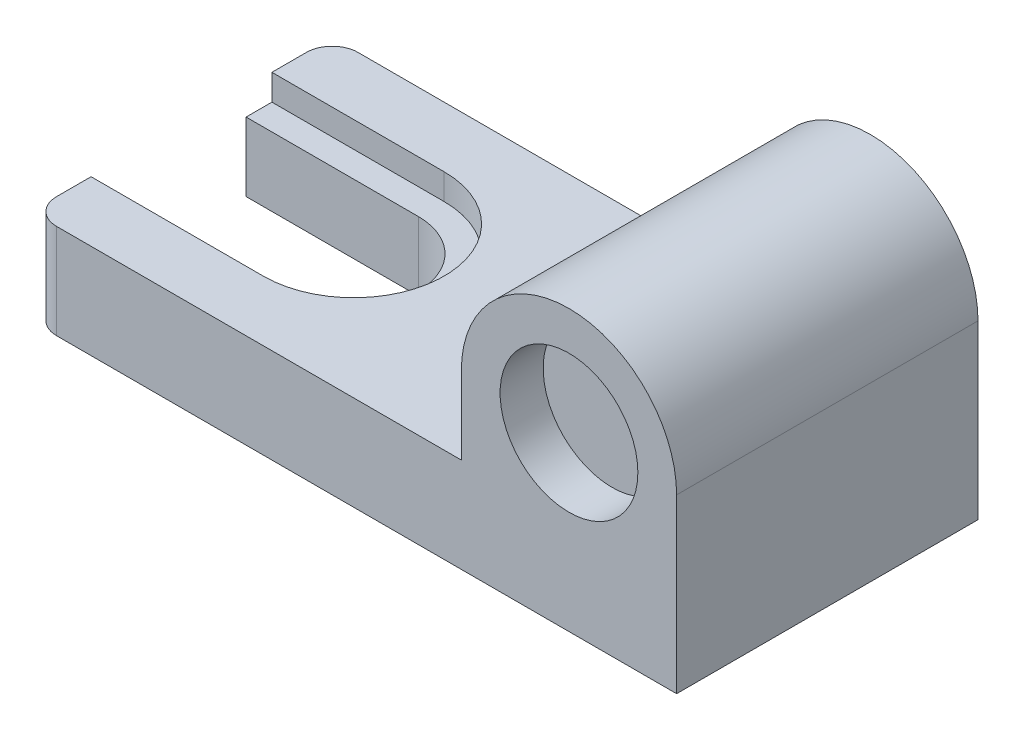
from build123d import *

# Parameters (mm, degrees)
IZIM1_W                     = 75
IZIM1_H                     = 36
Y_KSEKLIK_EKSTR_ZYON1_DEPTH = 35
IZIM2_W                     = 50
IZIM2_H                     = 25
KES_EKSTR_ZYON1_DEPTH       = 36
IZIM6_R                     = 8
KES_EKSTR_ZYON3_DEPTH       = 5
KES_EKSTR_ZYON4_DEPTH       = 3
KES_EKSTR_ZYON5_DEPTH       = 26
KES_EKSTR_ZYON5_DEPTH_BACK  = 12
RADYUS2_R                   = 3
RADYUS3_R                   = 3
KES_EKSTR_ZYON7_DEPTH       = 36


with BuildPart() as part:
    # Çizim1 → Yükseklik-Ekstrüzyon1 (new body)
    with BuildSketch(Plane.XY):
        with Locations((37.5, 18)):
            Rectangle(IZIM1_W, IZIM1_H)
    extrude(amount=Y_KSEKLIK_EKSTR_ZYON1_DEPTH)

    # Çizim2 → Kes-Ekstrüzyon1 (cut, through all)
    with BuildSketch(Plane.XY.offset(35)):
        with Locations((25, 23.5)):
            Rectangle(IZIM2_W, IZIM2_H)
    extrude(amount=-KES_EKSTR_ZYON1_DEPTH, mode=Mode.SUBTRACT)

    # Çizim6 → Kes-Ekstrüzyon3 (cut)
    with BuildSketch(Plane.XY.offset(35)):
        with Locations((62.5, 20)):
            Circle(IZIM6_R)
    extrude(amount=-KES_EKSTR_ZYON3_DEPTH, mode=Mode.SUBTRACT)

    # Çizim7 → Kes-Ekstrüzyon4 (cut)
    with BuildSketch(Plane(origin=(0, 11, 0), x_dir=(1, 0, 0), z_dir=(0, 1, 0))):
        with BuildLine():
            Line((0, -7), (20, -7))
            ThreePointArc((20, -7), (30.5, -17.5), (20, -28))
            Line((20, -28), (0, -28))
            Line((0, -28), (0, -25))
            Line((0, -25), (20, -25))
            ThreePointArc((20, -25), (27.5, -17.5), (20, -10))
            Line((20, -10), (0, -10))
            Line((0, -10), (0, -7))
        make_face()
    extrude(amount=-KES_EKSTR_ZYON4_DEPTH, mode=Mode.SUBTRACT)

    # Çizim8 → Kes-Ekstrüzyon5 (cut, two sides)
    with BuildSketch(Plane(origin=(0, 11, 0), x_dir=(1, 0, 0), z_dir=(0, 1, 0))) as kes_ekstr_zyon5_sk:
        with BuildLine():
            Line((0, -10), (20, -10))
            ThreePointArc((20, -10), (27.5, -17.5), (20, -25))
            Line((20, -25), (0, -25))
            Line((0, -25), (0, -10))
        make_face()
    extrude(amount=KES_EKSTR_ZYON5_DEPTH, mode=Mode.SUBTRACT)
    extrude(kes_ekstr_zyon5_sk.sketch, amount=-KES_EKSTR_ZYON5_DEPTH_BACK, mode=Mode.SUBTRACT)

    # Radyus2
    radyus2_edges = [part.edges().sort_by_distance(p)[0] for p in [
        (0, 5.5, 0),
    ]]
    fillet(radyus2_edges, radius=RADYUS2_R)

    # Radyus3
    radyus3_edges = [part.edges().sort_by_distance(p)[0] for p in [
        (0, 5.5, 35),
    ]]
    fillet(radyus3_edges, radius=RADYUS3_R)

    # Çizim9 → Kes-Ekstrüzyon7 (cut, through all)
    with BuildSketch(Plane.XY.offset(35)):
        with BuildLine():
            Line((50, 20), (50, 36))
            Line((50, 36), (75, 36))
            Line((75, 36), (75, 20))
            ThreePointArc((75, 20), (62.5, 32.5), (50, 20))
        make_face()
    extrude(amount=-KES_EKSTR_ZYON7_DEPTH, mode=Mode.SUBTRACT)


solid = part.part
